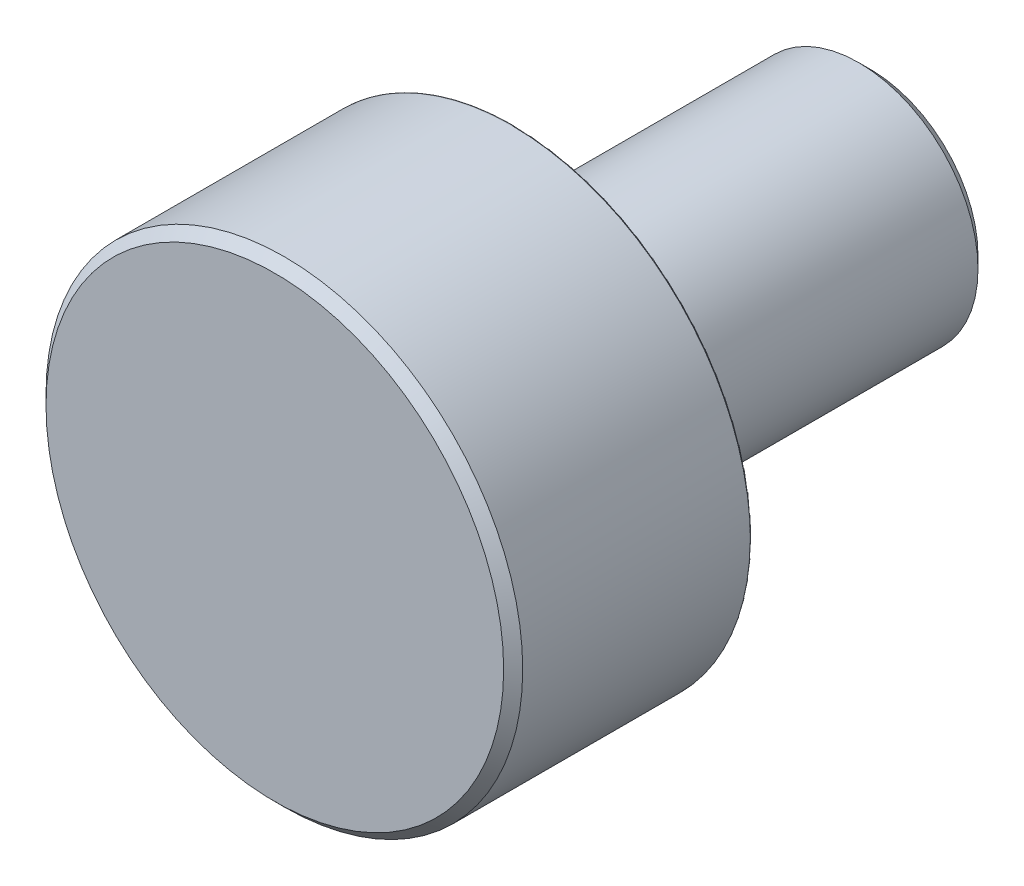
from build123d import *

# Parameters (mm, degrees)
CHAMFER1_SIZE = 0.32
CHAMFER2_SIZE = 0.4


with BuildPart() as part:
    # Sketch1 → Revolve1 (revolve)
    with BuildSketch(Plane(origin=(0, 0, 0), x_dir=(0, 0, -1), z_dir=(1, 0, 0))):
        with BuildLine():
            Line((-8, 0), (-8, 8))
            Line((-8, 8), (-0.05, 8))
            ThreePointArc((-0.05, 8), (-0.014644661, 7.985355339), (0, 7.95))
            Line((0, 7.95), (0, 4.447213595))
            ThreePointArc((0, 4.447213595), (-0.0127322, 4.413880262), (-0.044444444, 4.397523196))
            ThreePointArc((-0.044444444, 4.397523196), (-0.399380319, 3.977743298), (0, 3.6))
            Line((0, 3.6), (0.8, 3.6))
            Line((0.8, 3.6), (0.8, 4))
            Line((0.8, 4), (12, 4))
            Line((12, 4), (12, 0))
            Line((12, 0), (-8, 0))
        make_face()
    revolve(axis=Axis((0, 0, 12.7), (0, 0, -1)))

    # Chamfer1
    chamfer1_edges = [part.edges().sort_by_distance(p)[0] for p in [
        (0, -8, 8),
    ]]
    chamfer(chamfer1_edges, length=CHAMFER1_SIZE)

    # Chamfer2
    chamfer2_edges = [part.edges().sort_by_distance(p)[0] for p in [
        (0, -4, -12),
    ]]
    chamfer(chamfer2_edges, length=CHAMFER2_SIZE)


solid = part.part
